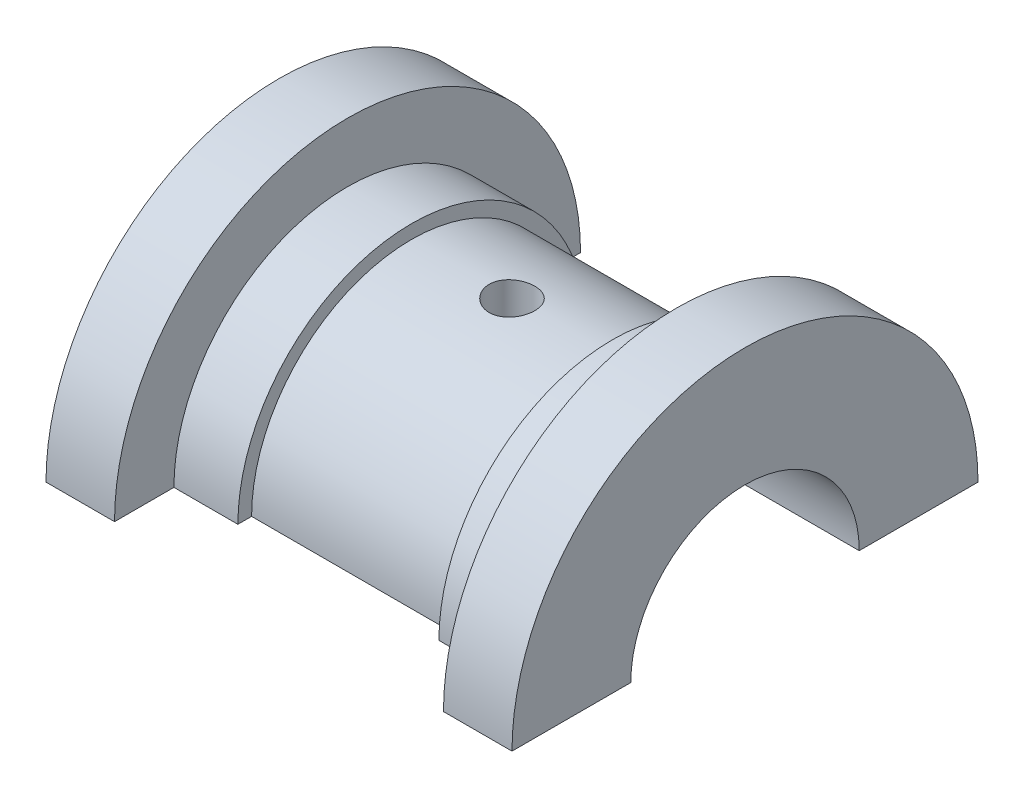
from build123d import *

# Parameters (mm, degrees)
REVOLVE1_ANGLE            = 180
F_5_0MM_DOWEL_HOLE1_D     = 5
F_5_0MM_DOWEL_HOLE1_DEPTH = 6
F_5_0MM_DOWEL_HOLE1_TIP   = 1.502151548


with BuildPart() as part:
    # Sketch1 → Revolve1 (revolve, symmetric)
    with BuildSketch(Plane.XY) as revolve1_sk:
        Polygon((-25.5, 12.5), (25.5, 12.5), (25.5, 25.5), (18, 25.5), (18, 19), (11, 19), (11, 17.5), (-11, 17.5), (-11, 19), (-18, 19), (-18, 25.5), (-25.5, 25.5), align=None)
    revolve(axis=Axis((0, 0, 0), (1, 0, 0)), revolution_arc=REVOLVE1_ANGLE / 2)
    revolve(revolve1_sk.sketch, axis=Axis((0, 0, 0), (-1, 0, 0)), revolution_arc=REVOLVE1_ANGLE / 2)

    # Ø5.0mm Dowel Hole1
    with Locations(Plane.ZX.offset(17.5)):
        with Locations((0, 0)):
            Hole(F_5_0MM_DOWEL_HOLE1_D / 2, depth=F_5_0MM_DOWEL_HOLE1_DEPTH)
            with Locations((0, 0, -(F_5_0MM_DOWEL_HOLE1_DEPTH + F_5_0MM_DOWEL_HOLE1_TIP / 2))):  # 118° drill point
                Cone(0, F_5_0MM_DOWEL_HOLE1_D / 2, F_5_0MM_DOWEL_HOLE1_TIP, mode=Mode.SUBTRACT)


solid = part.part
